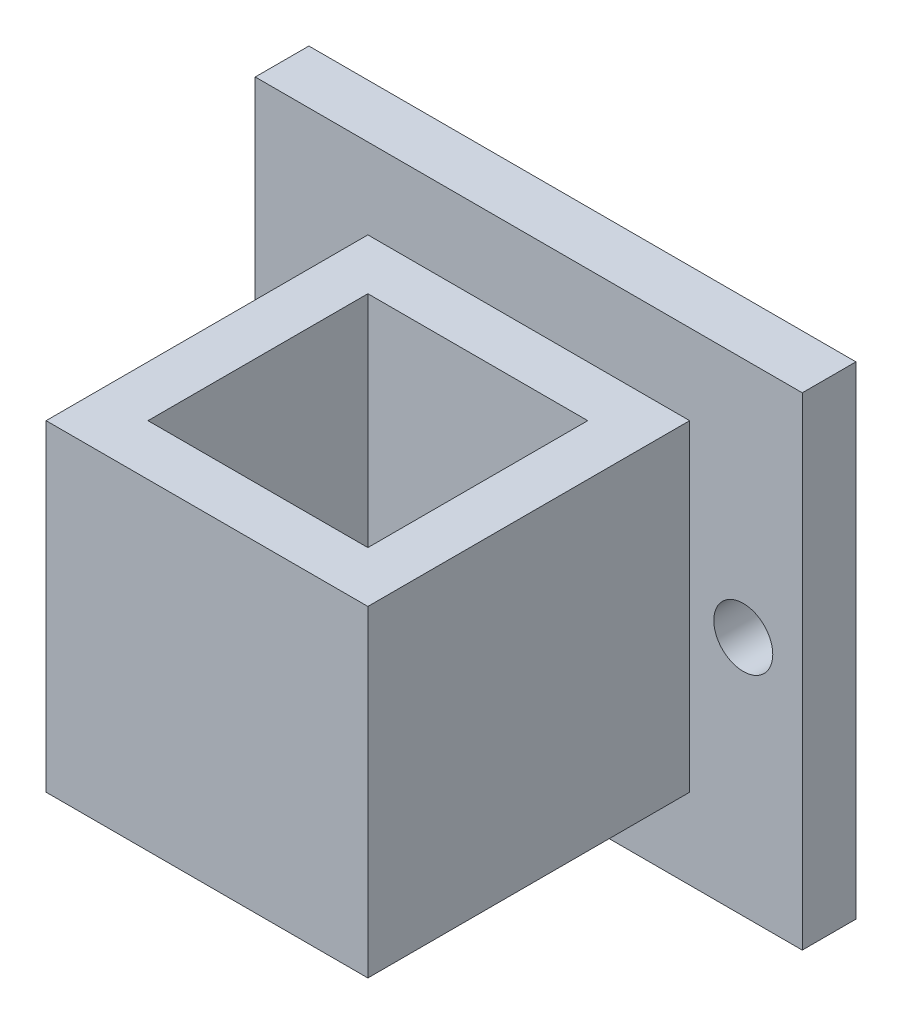
from build123d import *

# Parameters (mm, degrees)
SKETCH1_W           = 51
SKETCH1_H           = 45
BOSS_EXTRUDE1_DEPTH = 5
SKETCH2_W           = 30
SKETCH2_H           = 30
BOSS_EXTRUDE2_DEPTH = 30
SKETCH3_W           = 20.5
SKETCH3_H           = 20.5
CUT_EXTRUDE1_DEPTH  = 38.5
SKETCH4_R           = 2.75
CUT_EXTRUDE2_DEPTH  = 36


with BuildPart() as part:
    # Sketch1 → Boss-Extrude1 (new body)
    with BuildSketch(Plane.XY):
        with Locations((0, -37.5)):
            Rectangle(SKETCH1_W, SKETCH1_H)
    extrude(amount=BOSS_EXTRUDE1_DEPTH)

    # Sketch2 → Boss-Extrude2 (add)
    with BuildSketch(Plane.XY.offset(5)):
        with Locations((0, -37.5)):
            Rectangle(SKETCH2_W, SKETCH2_H)
    extrude(amount=BOSS_EXTRUDE2_DEPTH)

    # Sketch3 → Cut-Extrude1 (cut, through all)
    with BuildSketch(Plane.XZ.offset(52.5)):
        with Locations((0, 20)):
            Rectangle(SKETCH3_W, SKETCH3_H)
    extrude(amount=-CUT_EXTRUDE1_DEPTH, mode=Mode.SUBTRACT)

    # Sketch4 → Cut-Extrude2 (cut, through all)
    with BuildSketch(Plane(origin=(0, 0, 0), x_dir=(-1, 0, 0), z_dir=(0, 0, -1))):
        with Locations((20, -37.5)):
            Circle(SKETCH4_R)
        with Locations((-20, -37.5)):
            Circle(SKETCH4_R)
    extrude(amount=-CUT_EXTRUDE2_DEPTH, mode=Mode.SUBTRACT)


solid = part.part
